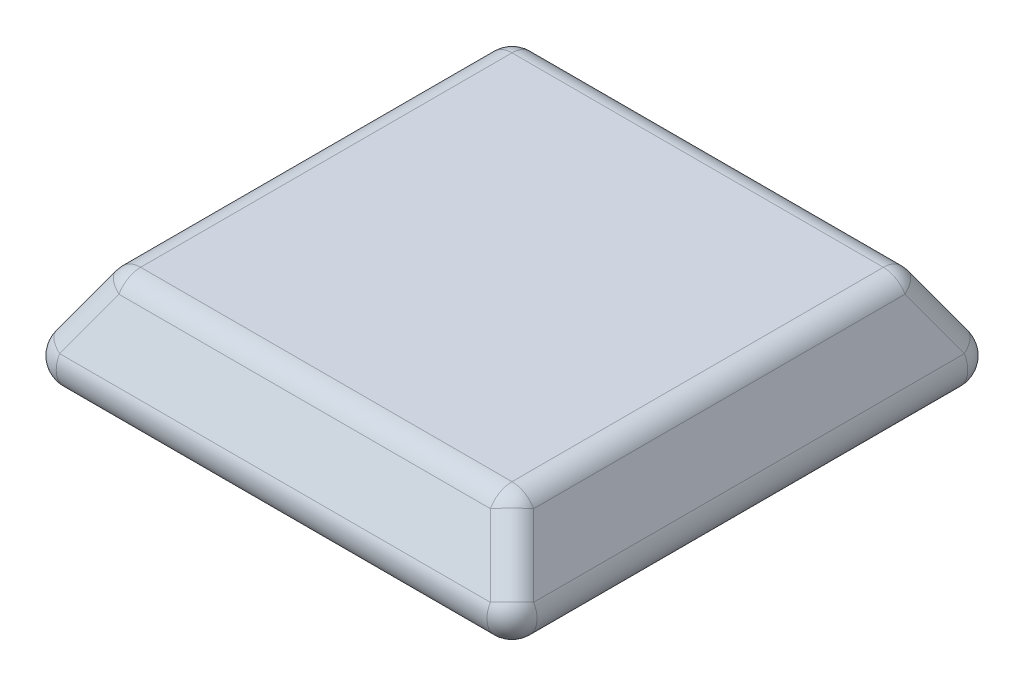
from build123d import *

# Parameters (mm, degrees)
SKETCH2_W           = 6200
SKETCH2_H           = 6200
BOSS_EXTRUDE1_DEPTH = 1216
BOSS_EXTRUDE1_TAPER = 30
FILLET1_R           = 300


with BuildPart() as part:
    # Sketch2 → Boss-Extrude1 (new body)
    with BuildSketch(Plane(origin=(0, 0, 0), x_dir=(1, 0, 0), z_dir=(0, 1, 0))):
        Rectangle(SKETCH2_W, SKETCH2_H)
    extrude(amount=BOSS_EXTRUDE1_DEPTH, taper=BOSS_EXTRUDE1_TAPER)

    # Fillet1
    fillet1_edges = [part.edges().sort_by_distance(p)[0] for p in [
        (-2397.942072665, 1216, 0),
        (0, 1216, 2397.942072665),
        (2397.942072665, 1216, 0),
        (0, 0, 3100),
        (-3100, 0, 0),
        (0, 0, -3100),
        (3100, 0, 0),
        (2748.971036333, 608, 2748.971036333),
        (-2748.971036333, 608, 2748.971036333),
        (-2748.971036333, 608, -2748.971036333),
        (2748.971036333, 608, -2748.971036333),
        (0, 1216, -2397.942072665),
    ]]
    fillet(fillet1_edges, radius=FILLET1_R)


solid = part.part
